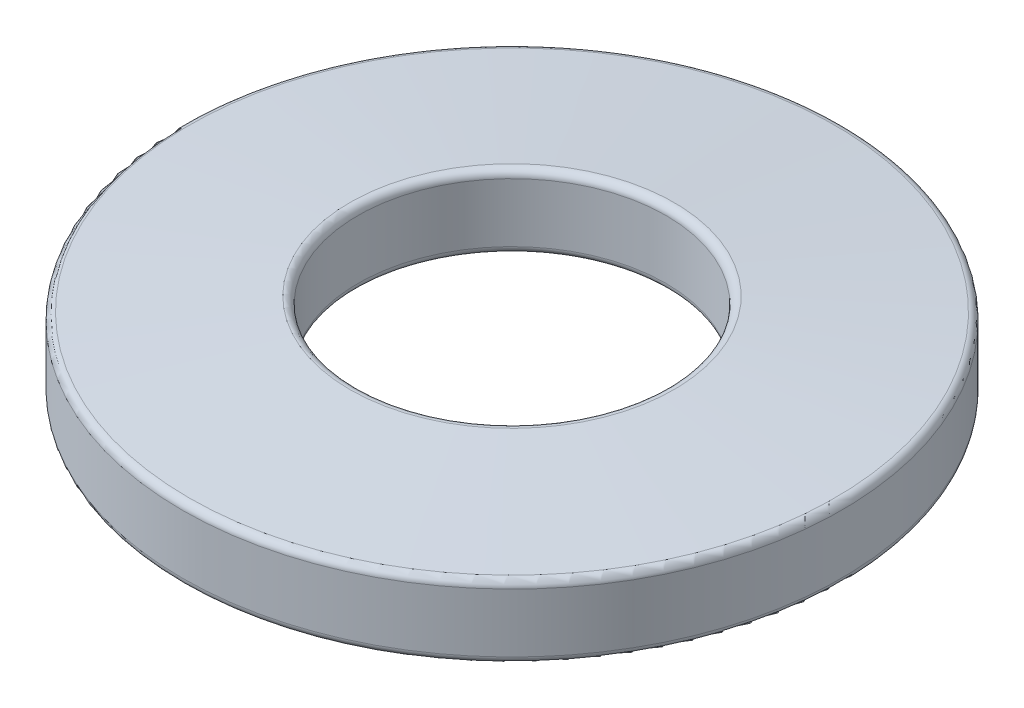
from build123d import *

# Parameters (mm, degrees)
FILLET1_R = 0.254


with BuildPart() as part:
    # Sketch2 → Revolve1 (revolve)
    with BuildSketch(Plane(origin=(0, 0, 0), x_dir=(0, 0, -1), z_dir=(1, 0, 0))):
        Polygon((5.3213, 3.048), (5.3213, 0.508), (11.3792, 0), (11.3792, 2.54), align=None)
    revolve(axis=Axis((0, 0, 0), (0, 1, 0)))

    # Fillet1
    fillet1_edges = [part.edges().sort_by_distance(p)[0] for p in [
        (0, 2.54, 11.3792),
        (0, 0, 11.3792),
        (0, 0.508, 5.3213),
        (0, 3.048, 5.3213),
    ]]
    fillet(fillet1_edges, radius=FILLET1_R)


solid = part.part
